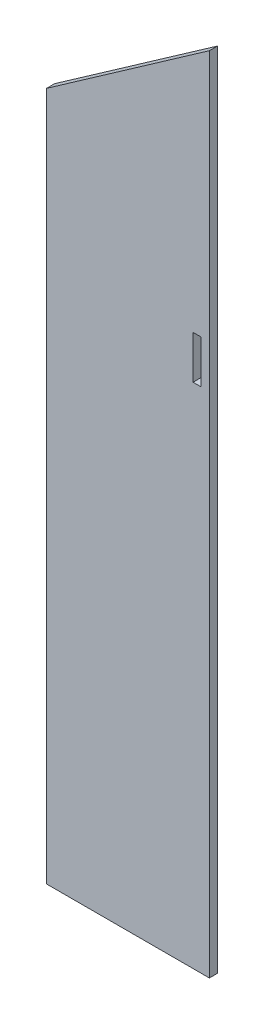
from build123d import *

# Parameters (mm, degrees)
BOSS_EXTRUDE1_DEPTH = 5
CUT_EXTRUDE1_REACH  = 7
SKETCH3_W           = 5
SKETCH3_H           = 26.5


with BuildPart() as part:
    # Sketch2 → Boss-Extrude1 (new body)
    with BuildSketch(Plane.XY):
        Polygon((-50, 422.98), (-50, 0), (50, 0), (50, 422.98), (50, 493.000753821), align=None)
    extrude(amount=BOSS_EXTRUDE1_DEPTH)

    # Sketch3 → Cut-Extrude1 (cut, up to next)
    with BuildSketch(Plane.XY.offset(5), mode=Mode.PRIVATE) as cut_extrude1_sk1:
        with Locations((42.5, 325)):
            Rectangle(SKETCH3_W, SKETCH3_H)
    cut_extrude1_tool1 = extrude(cut_extrude1_sk1.sketch, amount=-CUT_EXTRUDE1_REACH, mode=Mode.PRIVATE) & part.part
    add(cut_extrude1_tool1.solids().sort_by_distance((42.5, 325, 5))[0], mode=Mode.SUBTRACT)


solid = part.part
